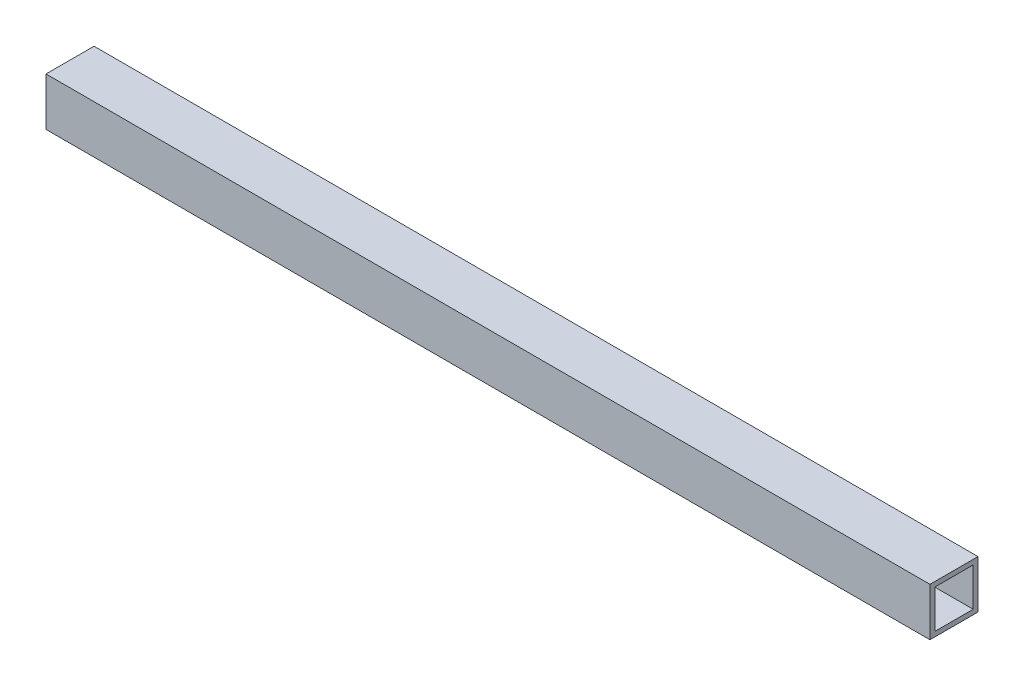
from build123d import *

# Parameters (mm, degrees)
SKETCH1_W           = 31.75
SKETCH1_H           = 31.75
SKETCH1_W_2         = 25.4
SKETCH1_H_2         = 25.4
EXTRUDE_THIN1_DEPTH = 584.2


with BuildPart() as part:
    # Sketch1 → Extrude-Thin1 (new body)
    with BuildSketch(Plane(origin=(0, 0, 0), x_dir=(0, 0, -1), z_dir=(1, 0, 0))):
        with Locations((12.7, 12.7)):
            Rectangle(SKETCH1_W, SKETCH1_H)
        with Locations((12.7, 12.7)):
            Rectangle(SKETCH1_W_2, SKETCH1_H_2, mode=Mode.SUBTRACT)
    extrude(amount=EXTRUDE_THIN1_DEPTH)


solid = part.part
